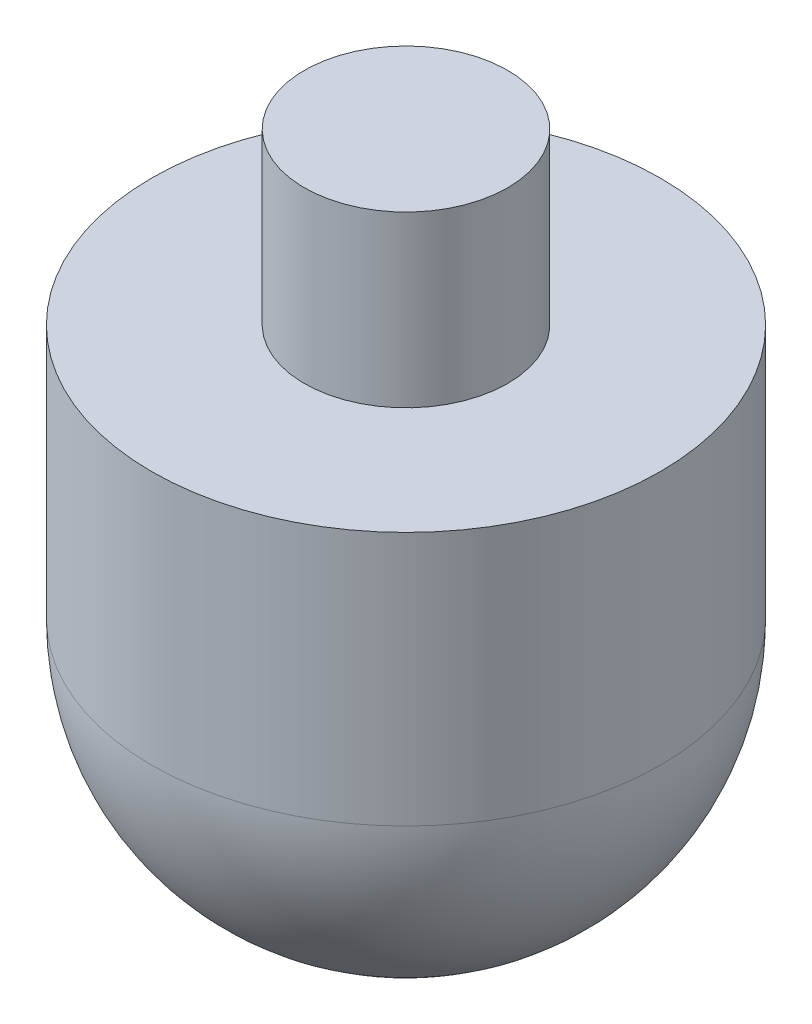
from build123d import *


with BuildPart() as part:
    # Sketch1 → Revolve1 (revolve)
    with BuildSketch(Plane.XY):
        with BuildLine():
            Line((0, -15), (0, 25))
            Line((0, 25), (6, 25))
            Line((6, 25), (6, 15))
            Line((6, 15), (15, 15))
            Line((15, 15), (15, 0))
            ThreePointArc((15, 0), (10.606601718, -10.606601718), (0, -15))
        make_face()
    revolve(axis=Axis((0, -24.365260496, 0), (0, 1, 0)))


solid = part.part
